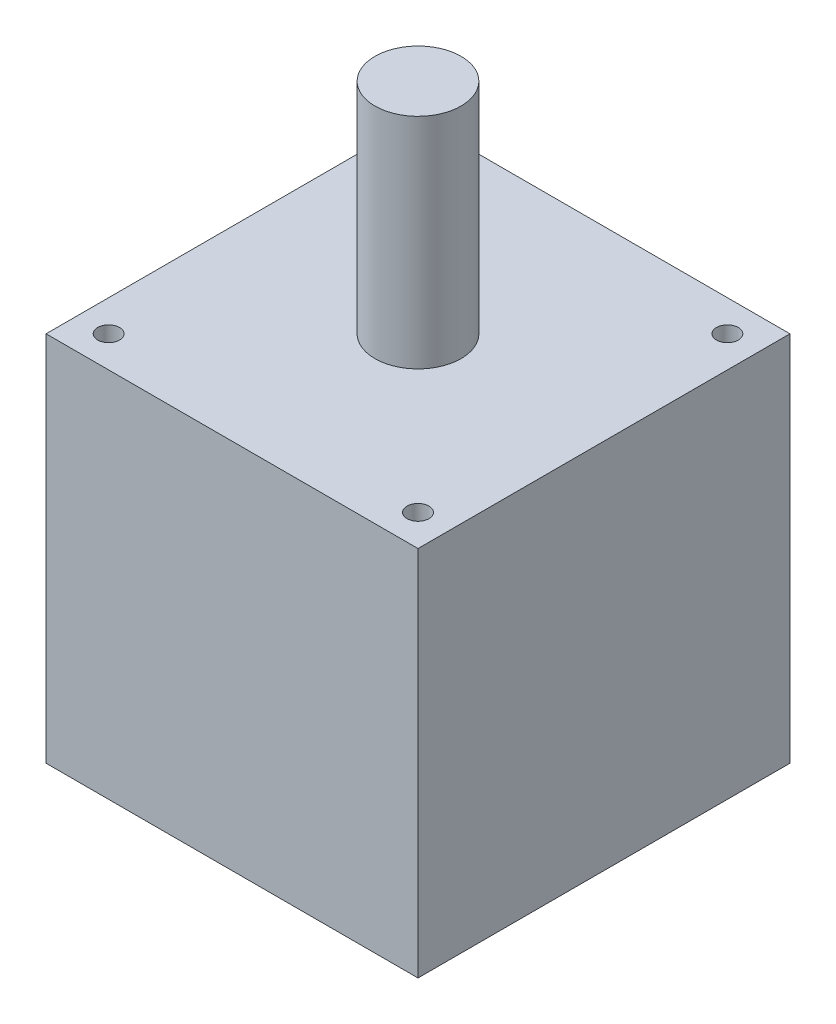
from build123d import *

# Parameters (mm, degrees)
SKETCH1_W            = 43.18
SKETCH1_H            = 43.18
BOSS_EXTRUDE1_DEPTH  = 43.18
SKETCH2_R            = 5
BOSS_EXTRUDE2_DEPTH  = 25.4
SKETCH3_R            = 1.27
CUT_EXTRUDE1_DEPTH   = 43.18
LPATTERN1_COUNT      = 2
LPATTERN1_PITCH      = 35.9156
LPATTERN1_COUNT_DIR2 = 2
LPATTERN1_PITCH_DIR2 = 35.9156


with BuildPart() as part:
    # Sketch1 → Boss-Extrude1 (new body)
    with BuildSketch(Plane(origin=(0, 0, 0), x_dir=(1, 0, 0), z_dir=(0, 1, 0))):
        Rectangle(SKETCH1_W, SKETCH1_H)
    extrude(amount=BOSS_EXTRUDE1_DEPTH)

    # Sketch2 → Boss-Extrude2 (add)
    with BuildSketch(Plane(origin=(0, 43.18, 0), x_dir=(1, 0, 0), z_dir=(0, 1, 0))):
        Circle(SKETCH2_R)
    extrude(amount=BOSS_EXTRUDE2_DEPTH)

    # Sketch3 → Cut-Extrude1 (cut)
    with BuildSketch(Plane(origin=(0, 43.18, 0), x_dir=(1, 0, 0), z_dir=(0, 1, 0))):
        with Locations((-17.960512242, 17.960512242)):
            Circle(SKETCH3_R)
    cut_extrude1 = extrude(amount=-CUT_EXTRUDE1_DEPTH, mode=Mode.SUBTRACT)

    # LPattern1: Cut-Extrude1 2 × 2
    with Locations(*[(i * LPATTERN1_PITCH, 0, j * LPATTERN1_PITCH_DIR2) for i in range(LPATTERN1_COUNT) for j in range(LPATTERN1_COUNT_DIR2) if (i, j) != (0, 0)]):
        add(cut_extrude1, mode=Mode.SUBTRACT)


solid = part.part
